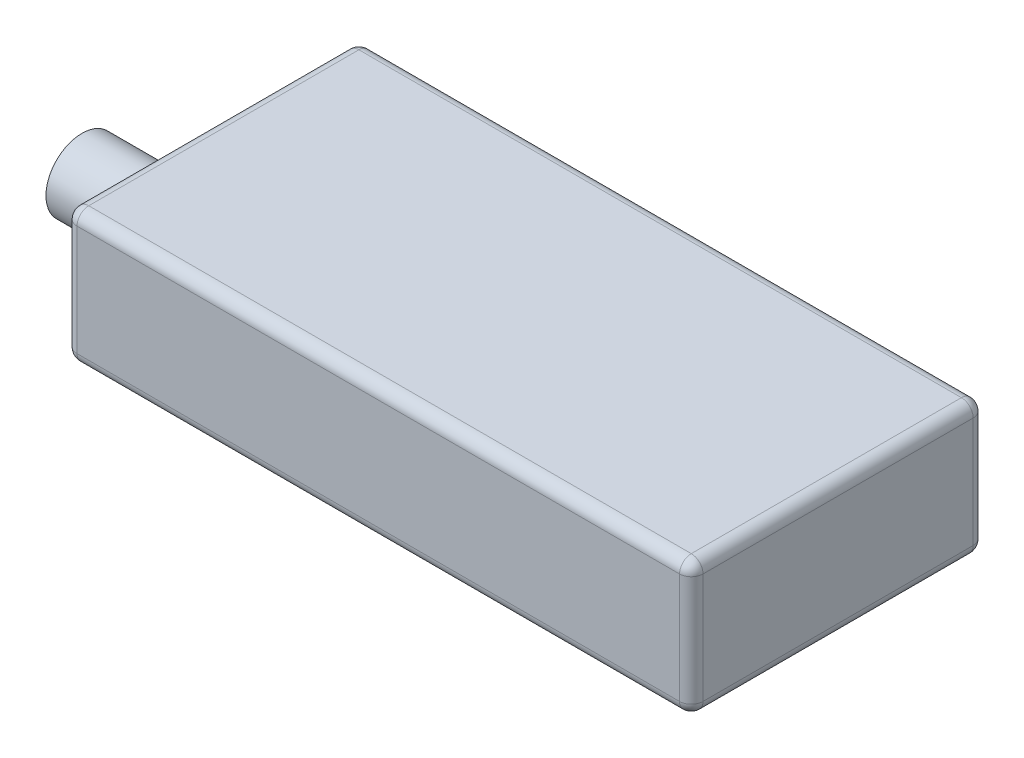
from build123d import *

# Parameters (mm, degrees)
SKETCH1_W           = 53.3
SKETCH1_H           = 25
BOSS_EXTRUDE1_DEPTH = 11.4
FILLET1_R           = 1
SKETCH2_R           = 3.065
BOSS_EXTRUDE2_DEPTH = 6.1


with BuildPart() as part:
    # Sketch1 → Boss-Extrude1 (new body)
    with BuildSketch(Plane(origin=(0, 0, 0), x_dir=(1, 0, 0), z_dir=(0, 1, 0))):
        Rectangle(SKETCH1_W, SKETCH1_H)
    extrude(amount=BOSS_EXTRUDE1_DEPTH)

    # Fillet1
    fillet1_edges = [part.edges().sort_by_distance(p)[0] for p in [
        (-26.65, 11.4, 0),
        (0, 11.4, 12.5),
        (26.65, 11.4, 0),
        (0, 0, 12.5),
        (-26.65, 0, 0),
        (0, 0, -12.5),
        (26.65, 0, 0),
        (26.65, 5.7, 12.5),
        (-26.65, 5.7, 12.5),
        (-26.65, 5.7, -12.5),
        (26.65, 5.7, -12.5),
        (0, 11.4, -12.5),
    ]]
    fillet(fillet1_edges, radius=FILLET1_R)

    # Sketch2 → Boss-Extrude2 (add)
    with BuildSketch(Plane.ZY.offset(26.65)):
        with Locations((4.975, 6.865)):
            Circle(SKETCH2_R)
    extrude(amount=BOSS_EXTRUDE2_DEPTH)


solid = part.part
